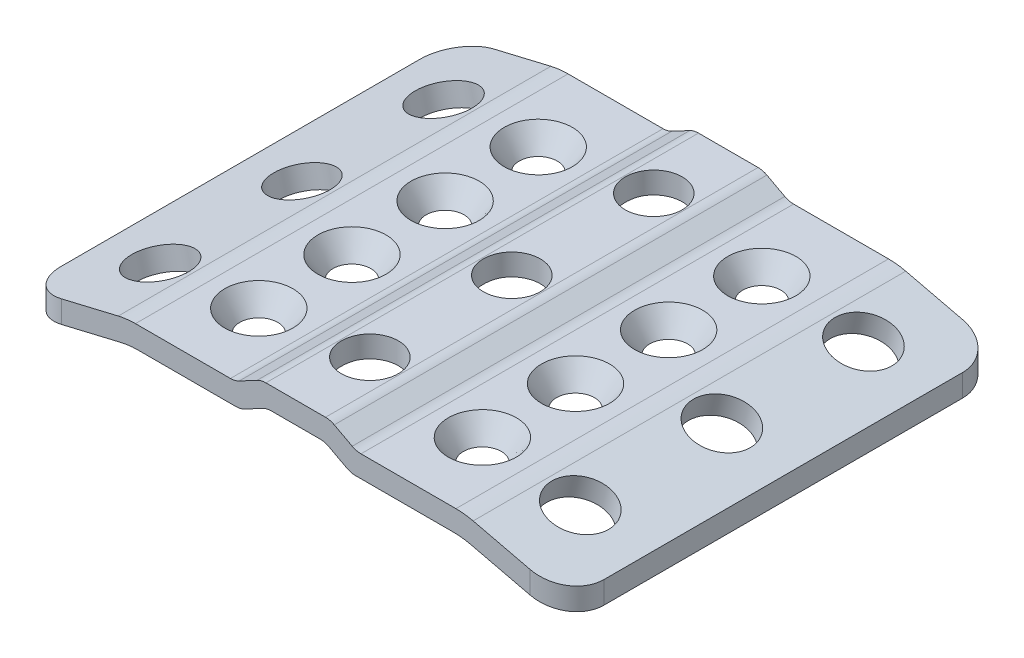
from build123d import *

# Parameters (mm, degrees)
BOSS_EXTRUDE1_DEPTH = 58.9788
FILLET3_R           = 5.0292
SKETCH2_R           = 3.9878
SKETCH2_R_2         = 3.937
CUT_EXTRUDE1_DEPTH  = 58.9788
SKETCH3_R           = 4.6482
CUT_EXTRUDE6_DEPTH  = 3.0988
CUT_EXTRUDE6_TAPER  = 35
SKETCH5_R           = 4.6482
CUT_EXTRUDE7_DEPTH  = 3.0988
CUT_EXTRUDE7_TAPER  = 35
SKETCH6_R           = 3.9878
CUT_EXTRUDE8_DEPTH  = 50.8
SKETCH7_R           = 3.8862
CUT_EXTRUDE9_DEPTH  = 50.8


with BuildPart() as part:
    # Sketch1 → Boss-Extrude1 (new body)
    with BuildSketch(Plane.XY):
        with BuildLine():
            Line((0, 0), (3.3274, 0))
            ThreePointArc((3.3274, 0), (3.943440488, -0.07583805), (4.522694118, -0.298823529))
            Line((4.522694118, -0.298823529), (6.965576471, -1.601694118))
            ThreePointArc((6.965576471, -1.601694118), (7.544830101, -1.824679597), (8.160870588, -1.900517647))
            Line((8.160870588, -1.900517647), (21.498585253, -1.900517647))
            ThreePointArc((21.498585253, -1.900517647), (22.681569141, -1.96962328), (23.848460342, -2.176000104))
            Line((23.848460342, -2.176000104), (36.989870588, -5.300145762))
            Line((36.989870588, -5.300145762), (36.989870588, -2.27162931))
            Line((36.989870588, -2.27162931), (24.193875089, 0.770399896))
            ThreePointArc((24.193875089, 0.770399896), (23.026983888, 0.97677672), (21.844, 1.045882353))
            Line((21.844, 1.045882353), (8.897470588, 1.045882353))
            ThreePointArc((8.897470588, 1.045882353), (8.281430101, 1.121720403), (7.702176471, 1.344705882))
            Line((7.702176471, 1.344705882), (5.259294118, 2.647576471))
            ThreePointArc((5.259294118, 2.647576471), (4.680040488, 2.87056195), (4.064, 2.9464))
            Line((4.064, 2.9464), (-4.064, 2.9464))
            ThreePointArc((-4.064, 2.9464), (-4.680040488, 2.87056195), (-5.259294118, 2.647576471))
            Line((-5.259294118, 2.647576471), (-7.702176471, 1.344705882))
            ThreePointArc((-7.702176471, 1.344705882), (-8.281430101, 1.121720403), (-8.897470588, 1.045882353))
            Line((-8.897470588, 1.045882353), (-21.844, 1.045882353))
            ThreePointArc((-21.844, 1.045882353), (-23.026983888, 0.97677672), (-24.193875089, 0.770399896))
            Line((-24.193875089, 0.770399896), (-36.989870588, -2.27162931))
            Line((-36.989870588, -2.27162931), (-36.989870588, -5.300145762))
            Line((-36.989870588, -5.300145762), (-23.848460342, -2.176000104))
            ThreePointArc((-23.848460342, -2.176000104), (-22.681569141, -1.96962328), (-21.498585253, -1.900517647))
            Line((-21.498585253, -1.900517647), (-8.160870588, -1.900517647))
            ThreePointArc((-8.160870588, -1.900517647), (-7.544830101, -1.824679597), (-6.965576471, -1.601694118))
            Line((-6.965576471, -1.601694118), (-4.522694118, -0.298823529))
            ThreePointArc((-4.522694118, -0.298823529), (-3.943440488, -0.07583805), (-3.3274, 0))
            Line((-3.3274, 0), (0, 0))
        make_face()
    extrude(amount=BOSS_EXTRUDE1_DEPTH)

    # Fillet3
    fillet3_edges = [part.edges().sort_by_distance(p)[0] for p in [
        (-36.989870588, -3.785887536, 0),
        (36.989870588, -3.785887536, 0),
        (36.989870588, -3.785887536, 58.9788),
        (-36.989870588, -3.785887536, 58.9788),
    ]]
    fillet(fillet3_edges, radius=FILLET3_R)

    # Sketch2 → Cut-Extrude1 (cut)
    with BuildSketch(Plane(origin=(-1.467570487, 6.173190353, 0), x_dir=(0.972885585, 0.231286918, 0), z_dir=(-0.231286918, 0.972885585, 0))):
        with Locations((-27.927110028, -10.1854)):
            Circle(SKETCH2_R)
        with Locations((-27.927110028, -29.4894)):
            Circle(SKETCH2_R_2)
        with Locations((-27.927110028, -48.8188)):
            Circle(SKETCH2_R)
    extrude(amount=-CUT_EXTRUDE1_DEPTH, mode=Mode.SUBTRACT)

    # Sketch3 → Cut-Extrude6 (cut)
    with BuildSketch(Plane(origin=(0, 1.045882353, 0), x_dir=(1, 0, 0), z_dir=(0, 1, 0))):
        with Locations((-15.24, -10.668)):
            Circle(SKETCH3_R)
        with Locations((-15.24, -23.368)):
            Circle(SKETCH3_R)
        with Locations((-15.24, -36.068)):
            Circle(SKETCH3_R)
        with Locations((-15.24, -48.768)):
            Circle(SKETCH3_R)
    extrude(amount=-CUT_EXTRUDE6_DEPTH, taper=CUT_EXTRUDE6_TAPER, mode=Mode.SUBTRACT)

    # Sketch5 → Cut-Extrude7 (cut)
    with BuildSketch(Plane(origin=(0, 1.045882353, 0), x_dir=(1, 0, 0), z_dir=(0, 1, 0))):
        with Locations((15.24, -10.668)):
            Circle(SKETCH5_R)
        with Locations((15.24, -23.368)):
            Circle(SKETCH5_R)
        with Locations((15.24, -36.068)):
            Circle(SKETCH5_R)
        with Locations((15.24, -48.768)):
            Circle(SKETCH5_R)
    extrude(amount=-CUT_EXTRUDE7_DEPTH, taper=CUT_EXTRUDE7_TAPER, mode=Mode.SUBTRACT)

    # Sketch6 → Cut-Extrude8 (cut)
    with BuildSketch(Plane(origin=(1.467570487, 6.173190353, 0), x_dir=(0.972885585, -0.231286918, 0), z_dir=(0.231286918, 0.972885585, 0))):
        with Locations((27.876310028, -10.16)):
            Circle(SKETCH6_R)
        with Locations((27.876310028, -29.464)):
            Circle(SKETCH6_R)
        with Locations((27.876310028, -48.768)):
            Circle(SKETCH6_R)
    extrude(amount=-CUT_EXTRUDE8_DEPTH, mode=Mode.SUBTRACT)

    # Sketch7 → Cut-Extrude9 (cut)
    with BuildSketch(Plane(origin=(0, 2.9464, 0), x_dir=(1, 0, 0), z_dir=(0, 1, 0))):
        with Locations((0, -10.16)):
            Circle(SKETCH7_R)
        with Locations((0, -29.5148)):
            Circle(SKETCH7_R)
        with Locations((0, -48.8696)):
            Circle(SKETCH7_R)
    extrude(amount=-CUT_EXTRUDE9_DEPTH, mode=Mode.SUBTRACT)


solid = part.part
